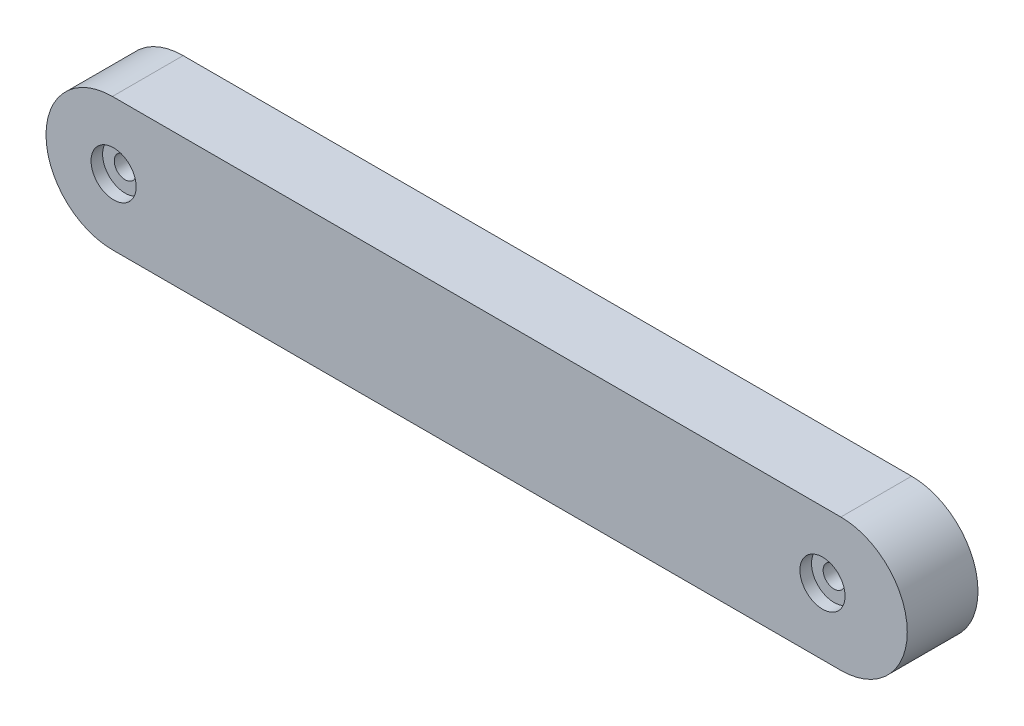
from build123d import *

# Parameters (mm, degrees)
BOSS_EXTRUDE1_DEPTH                                 = 10.568712475
CBORE_FOR_4_BINDING_HEAD_MACHINE_SCREW1_D           = 3.2639
CBORE_FOR_4_BINDING_HEAD_MACHINE_SCREW1_CBORE_D     = 6.74624
CBORE_FOR_4_BINDING_HEAD_MACHINE_SCREW1_CBORE_DEPTH = 1.7272
CBORE_FOR_4_BINDING_HEAD_MACHINE_SCREW2_D           = 3.2639
CBORE_FOR_4_BINDING_HEAD_MACHINE_SCREW2_CBORE_D     = 6.74624
CBORE_FOR_4_BINDING_HEAD_MACHINE_SCREW2_CBORE_DEPTH = 1.7272


with BuildPart() as part:
    # Sketch1 → Boss-Extrude1 (new body)
    with BuildSketch(Plane.XY):
        with BuildLine():
            Line((0, -9.926359007), (-108.863033935, -9.926359007))
            ThreePointArc((-108.863033935, -9.926359007), (-118.789392942, 0), (-108.863033935, 9.926359007))
            Line((-108.863033935, 9.926359007), (0, 9.926359007))
            ThreePointArc((0, 9.926359007), (9.926359007, 0), (0, -9.926359007))
        make_face()
    extrude(amount=BOSS_EXTRUDE1_DEPTH)

    # CBORE for #4 Binding Head Machine Screw1 (through all)
    with Locations(Plane.XY.offset(10.568712475)):
        with Locations((-2.744321225, 0)):
            CounterBoreHole(CBORE_FOR_4_BINDING_HEAD_MACHINE_SCREW1_D / 2, CBORE_FOR_4_BINDING_HEAD_MACHINE_SCREW1_CBORE_D / 2, CBORE_FOR_4_BINDING_HEAD_MACHINE_SCREW1_CBORE_DEPTH)

    # CBORE for #4 Binding Head Machine Screw2 (through all)
    with Locations(Plane.XY.offset(10.568712475)):
        with Locations((-108.687959282, 0)):
            CounterBoreHole(CBORE_FOR_4_BINDING_HEAD_MACHINE_SCREW2_D / 2, CBORE_FOR_4_BINDING_HEAD_MACHINE_SCREW2_CBORE_D / 2, CBORE_FOR_4_BINDING_HEAD_MACHINE_SCREW2_CBORE_DEPTH)


solid = part.part
